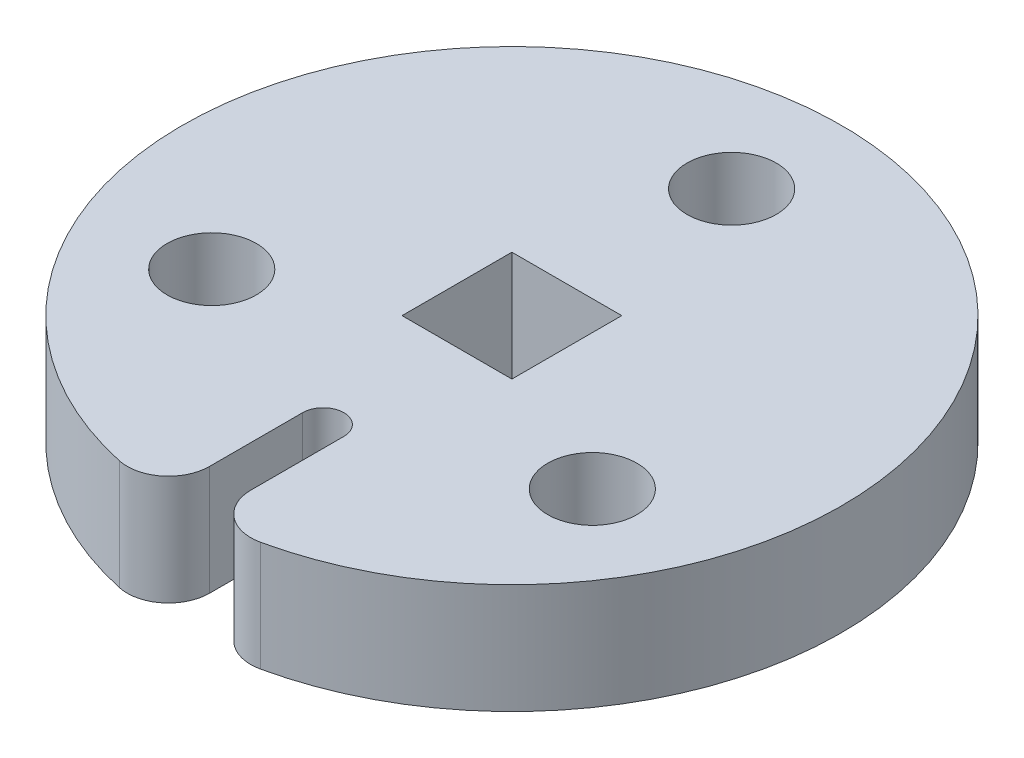
from build123d import *

# Parameters (mm, degrees)
SKETCH1_R           = 2.5796875
SKETCH1_W           = 6.35
SKETCH1_H           = 6.35
BOSS_EXTRUDE1_DEPTH = 6.35


with BuildPart() as part:
    # Sketch1 → Boss-Extrude1 (new body)
    with BuildSketch(Plane(origin=(0, 0, 0), x_dir=(1, 0, 0), z_dir=(0, 1, 0))):
        with BuildLine():
            Line((-1.190625, -10.903378281), (-1.190625, -16.281552001))
            ThreePointArc((-1.190625, -16.281552001), (-2.079347575, -18.137007052), (-4.082142857, -18.607488001))
            ThreePointArc((-4.082142857, -18.607488001), (0, 19.05), (4.082142857, -18.607488001))
            ThreePointArc((4.082142857, -18.607488001), (2.079347575, -18.137007052), (1.190625, -16.281552001))
            Line((1.190625, -16.281552001), (1.190625, -10.903378281))
            ThreePointArc((1.190625, -10.903378281), (0, -9.712753281), (-1.190625, -10.903378281))
        make_face()
        with Locations((0, 12.7)):
            Circle(SKETCH1_R, mode=Mode.SUBTRACT)
        with Locations((10.998522628, -6.35)):
            Circle(SKETCH1_R, mode=Mode.SUBTRACT)
        with Locations((-10.998522628, -6.35)):
            Circle(SKETCH1_R, mode=Mode.SUBTRACT)
        Rectangle(SKETCH1_W, SKETCH1_H, mode=Mode.SUBTRACT)
    extrude(amount=BOSS_EXTRUDE1_DEPTH)


solid = part.part
